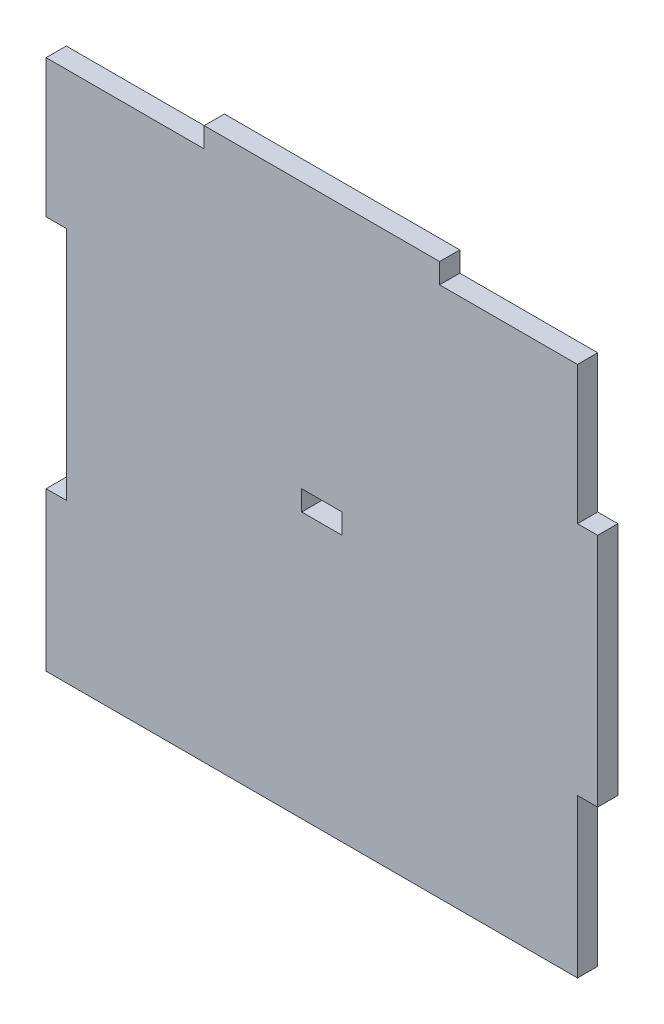
from build123d import *

# Parameters (mm, degrees)
BOSS_EXTRUDE1_DEPTH = 3
SKETCH2_W           = 6
SKETCH2_H           = 3
CUT_EXTRUDE1_DEPTH  = 3


with BuildPart() as part:
    # Sketch1 → Boss-Extrude1 (new body)
    with BuildSketch(Plane.XY):
        Polygon((-38, 39.5), (-17.5, 39.5), (-17.5, 42.5), (17.5, 42.5), (17.5, 39.5), (38, 39.5), (38, 19), (41, 19), (41, 16), (41, -16), (38, -16), (38, -19), (38, -39.5), (-41, -39.5), (-41, -19), (-41, -16), (-38, -16), (-38, 16), (-38, 19), (-41, 19), (-41, 39.5), align=None)
    extrude(amount=BOSS_EXTRUDE1_DEPTH)

    # Sketch2 → Cut-Extrude1 (cut)
    with BuildSketch(Plane.XY.offset(3)):
        with Locations((0, 1.5)):
            Rectangle(SKETCH2_W, SKETCH2_H)
    extrude(amount=-CUT_EXTRUDE1_DEPTH, mode=Mode.SUBTRACT)


solid = part.part
